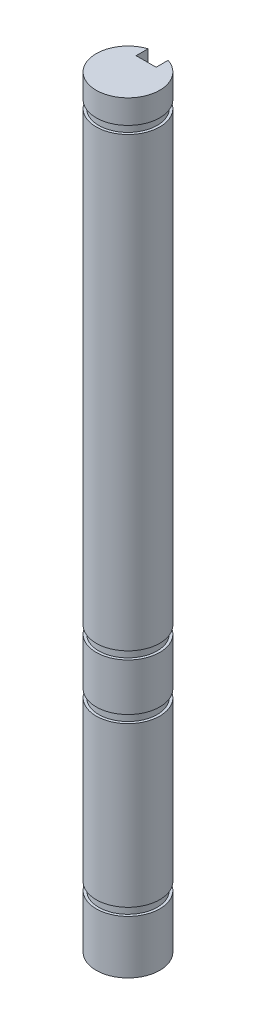
from build123d import *

# Parameters (mm, degrees)
BOSS_EXTRUDE1_DEPTH = 76.2
CUT_EXTRUDE1_START  = -3.175
SKETCH2_R           = 3.175
SKETCH2_R_2         = 2.921
CUT_EXTRUDE1_DEPTH  = 0.7874
CUT_EXTRUDE2_START  = -28.321
SKETCH3_R           = 3.175
SKETCH3_R_2         = 2.921
CUT_EXTRUDE2_DEPTH  = 0.7874
CUT_EXTRUDE3_START  = -22.8092
SKETCH3_6_R         = 3.175
SKETCH3_6_R_2       = 2.921
CUT_EXTRUDE3_DEPTH  = 0.7874
CUT_EXTRUDE4_START  = -6.1214
SKETCH3_7_R         = 3.175
SKETCH3_7_R_2       = 2.921
CUT_EXTRUDE4_DEPTH  = 0.7874


with BuildPart() as part:
    # Sketch1 → Boss-Extrude1 (new body)
    with BuildSketch(Plane(origin=(0, 0, 0), x_dir=(1, 0, 0), z_dir=(0, 1, 0))):
        with BuildLine():
            Line((-1, 3.01340754), (-1, 1.81340754))
            Line((-1, 1.81340754), (1, 1.81340754))
            Line((1, 1.81340754), (1, 3.01340754))
            ThreePointArc((1, 3.01340754), (0, -3.175), (-1, 3.01340754))
        make_face()
    extrude(amount=BOSS_EXTRUDE1_DEPTH)

    # Sketch2 → Cut-Extrude1 (cut)
    with BuildSketch(Plane(origin=(0, 76.2, 0), x_dir=(1, 0, 0), z_dir=(0, 1, 0)).offset(CUT_EXTRUDE1_START)):
        Circle(SKETCH2_R)
        Circle(SKETCH2_R_2, mode=Mode.SUBTRACT)
    extrude(amount=CUT_EXTRUDE1_DEPTH, mode=Mode.SUBTRACT)

    # Sketch3 → Cut-Extrude2 (cut)
    with BuildSketch(Plane(origin=(0, 0, 0), x_dir=(0, 0, -1), z_dir=(0, -1, 0)).offset(CUT_EXTRUDE2_START)):
        Circle(SKETCH3_R)
        Circle(SKETCH3_R_2, mode=Mode.SUBTRACT)
    extrude(amount=CUT_EXTRUDE2_DEPTH, mode=Mode.SUBTRACT)

    # Sketch3_6 → Cut-Extrude3 (cut)
    with BuildSketch(Plane(origin=(0, 0, 0), x_dir=(0, 0, -1), z_dir=(0, -1, 0)).offset(CUT_EXTRUDE3_START)):
        Circle(SKETCH3_6_R)
        Circle(SKETCH3_6_R_2, mode=Mode.SUBTRACT)
    extrude(amount=CUT_EXTRUDE3_DEPTH, mode=Mode.SUBTRACT)

    # Sketch3_7 → Cut-Extrude4 (cut)
    with BuildSketch(Plane(origin=(0, 0, 0), x_dir=(0, 0, -1), z_dir=(0, -1, 0)).offset(CUT_EXTRUDE4_START)):
        Circle(SKETCH3_7_R)
        Circle(SKETCH3_7_R_2, mode=Mode.SUBTRACT)
    extrude(amount=CUT_EXTRUDE4_DEPTH, mode=Mode.SUBTRACT)


solid = part.part
